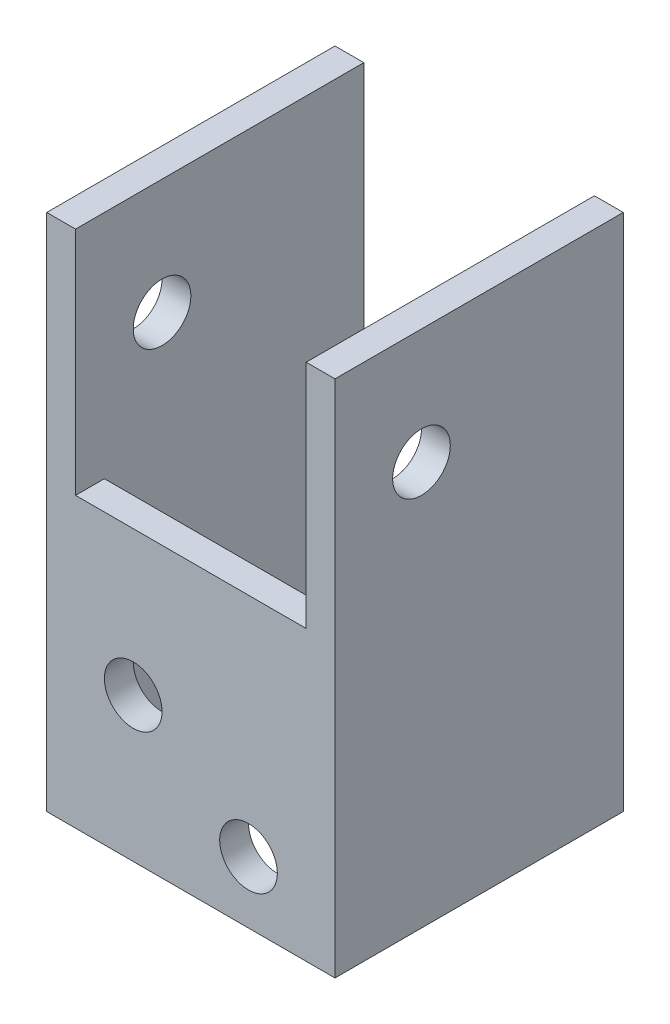
from build123d import *

# Parameters (mm, degrees)
SKETCH1_W                   = 31.75
SKETCH1_H                   = 31.75
SKETCH1_W_2                 = 25.4
SKETCH1_H_2                 = 25.4
BOSS_EXTRUDE1_DEPTH         = 57.15
F_1_4_0_25_DIAMETER_HOLE5_D = 6.35
SKETCH16_W                  = 25.4
SKETCH16_H                  = 57.15
CUT_EXTRUDE1_DEPTH          = 5.08
F_1_4_0_25_DIAMETER_HOLE7_D = 6.35
SKETCH20_W                  = 25.4
SKETCH20_H                  = 25.4
CUT_EXTRUDE2_DEPTH          = 5.08


with BuildPart() as part:
    # Sketch1 → Boss-Extrude1 (new body)
    with BuildSketch(Plane(origin=(0, 0, 0), x_dir=(1, 0, 0), z_dir=(0, 1, 0))):
        with Locations((15.875, 15.875)):
            Rectangle(SKETCH1_W, SKETCH1_H)
        with Locations((15.875, 15.875)):
            Rectangle(SKETCH1_W_2, SKETCH1_H_2, mode=Mode.SUBTRACT)
    extrude(amount=BOSS_EXTRUDE1_DEPTH)

    # 1/4 (0.25) Diameter Hole5 (through all)
    with Locations(Plane(origin=(31.75, 0, 0), x_dir=(0, 0, -1), z_dir=(1, 0, 0))):
        with Locations((9.525, 44.45)):
            Hole(F_1_4_0_25_DIAMETER_HOLE5_D / 2)

    # Sketch16 → Cut-Extrude1 (cut)
    with BuildSketch(Plane(origin=(0, 0, -31.75), x_dir=(-1, 0, 0), z_dir=(0, 0, -1))):
        with Locations((-15.875, 28.575)):
            Rectangle(SKETCH16_W, SKETCH16_H)
    extrude(amount=-CUT_EXTRUDE1_DEPTH, mode=Mode.SUBTRACT)

    # 1/4 (0.25) Diameter Hole7 (through all)
    with Locations(Plane.XY):
        with Locations((22.225, 6.803571429), (9.525, 15.875)):
            Hole(F_1_4_0_25_DIAMETER_HOLE7_D / 2)

    # Sketch20 → Cut-Extrude2 (cut)
    with BuildSketch(Plane.XY):
        with Locations((15.875, 44.45)):
            Rectangle(SKETCH20_W, SKETCH20_H)
    extrude(amount=-CUT_EXTRUDE2_DEPTH, mode=Mode.SUBTRACT)


solid = part.part
